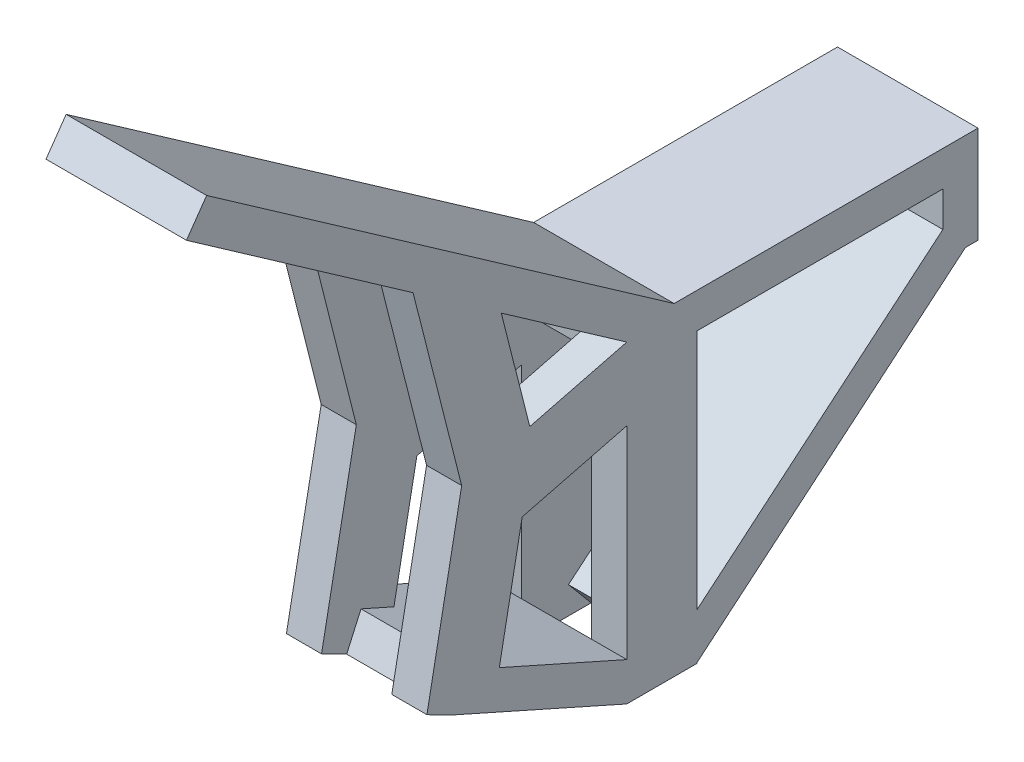
from build123d import *

# Parameters (mm, degrees)
SKETCH_1_W       = 160
SKETCH_1_H       = 40
EXTRUDE_1_DEPTH  = 400
EXTRUDE_6_DEPTH  = 160
SKETCH_11_W      = 40
SKETCH_11_H      = 40
EXTRUDE_7_DEPTH  = 160
EXTRUDE_11_DEPTH = 160
SKETCH_17_W      = 40
SKETCH_17_H      = 80
EXTRUDE_13_DEPTH = 328
EXTRUDE_17_DEPTH = 160
EXTRUDE_18_DEPTH = 40
SKETCH_29_W      = 40
SKETCH_29_H      = 210
EXTRUDE_19_DEPTH = 80
EXTRUDE_20_DEPTH = 40
EXTRUDE_21_DEPTH = 40
EXTRUDE_22_DEPTH = 40


with BuildPart() as part:
    # Эскиз1 → Бобышка-Вытянуть1 (new body)
    with BuildSketch(Plane.XY):
        with Locations((41.709401709, 20)):
            Rectangle(SKETCH_1_W, SKETCH_1_H)
    extrude(amount=EXTRUDE_1_DEPTH)

    # Эскиз8 → Бобышка-Вытянуть6 (add)
    with BuildSketch(Plane.ZY.offset(38.290598291)):
        Polygon((403.40525509, 80.13918018), (346.080564925, 40), (400, 40), (400, 28.923811345), (901.472451167, 380.058601857), (878.529393713, 412.824683628), align=None)
    extrude(amount=-EXTRUDE_6_DEPTH)

    # Эскиз11 → Бобышка-Вытянуть7 (add)
    with BuildSketch(Plane.ZY.offset(38.290598291)):
        with Locations((20, -20)):
            Rectangle(SKETCH_11_W, SKETCH_11_H)
    extrude(amount=-EXTRUDE_7_DEPTH)

    # Эскиз12 → Бобышка-Вытянуть11 (add)
    with BuildSketch(Plane.ZY.offset(38.290598291)):
        Polygon((346.417777248, -297.115043875), (40, -40), (0, -40), (0, -70.641777725), (14.288495613, -70.641777725), (320.70627286, -327.756821599), align=None)
    extrude(amount=-EXTRUDE_11_DEPTH)

    # Эскиз17 → Бобышка-Вытянуть13 (add)
    with BuildSketch(Plane(origin=(0, 0, 0), x_dir=(-1, 0, 0), z_dir=(0, -1, 0))):
        with Locations((18.290598291, -360)):
            Rectangle(SKETCH_17_W, SKETCH_17_H)
        with Locations((-101.709401709, -360)):
            Rectangle(SKETCH_17_W, SKETCH_17_H)
    extrude(amount=EXTRUDE_13_DEPTH)

    # Эскиз26 → Бобышка-Вытянуть17 (add)
    with BuildSketch(Plane.ZY.offset(38.290598291)):
        Polygon((400, -284.21454886), (400, -328), (416.269465723, -320.756367165), align=None)
        Polygon((582.709091529, -202.867220245), (598.978557252, -239.40903855), (416.269465723, -320.756367165), (400, -284.21454886), align=None)
    extrude(amount=-EXTRUDE_17_DEPTH)

    # Эскиз27 → Бобышка-Вытянуть18 (add)
    with BuildSketch(Plane.ZY.offset(38.290598291)):
        Polygon((509.482462661, -33.639974138), (588.04709667, -18.55361331), (616.334023223, -165.862302077), (537.769389214, -180.948662905), align=None)
        Polygon((545.18630579, -219.573440808), (582.709091529, -202.867220245), (595.238756951, -231.009309548), (627.648793843, -224.785777584), (616.334023223, -165.862302077), (537.769389214, -180.948662905), align=None)
        Polygon((627.648793843, -224.785777584), (595.238756951, -231.009309548), (598.978557252, -239.40903855), align=None)
    extrude(amount=-EXTRUDE_18_DEPTH)

    # Эскиз29 → Бобышка-Вытянуть19 (add)
    with BuildSketch(Plane(origin=(0, 108.244163778, 563.698774535), x_dir=(1, 0, 0), z_dir=(0, 0.18857951034822912, 0.9820579251127819))):
        with Locations((101.709401709, -234.114356543)):
            Rectangle(SKETCH_29_W, SKETCH_29_H)
    extrude(amount=-EXTRUDE_19_DEPTH)

    # Эскиз33 → Бобышка-Вытянуть20 (add)
    with BuildSketch(Plane(origin=(121.709401709, 0, 0), x_dir=(0, 0, -1), z_dir=(1, 0, 0))):
        Polygon((-627.648793843, -224.785777584), (-598.978557252, -239.40903855), (-595.238756951, -231.009309548), align=None)
    extrude(amount=-EXTRUDE_20_DEPTH)

    # Эскиз34 → Бобышка-Вытянуть21 (add)
    with BuildSketch(Plane.ZY.offset(38.290598291)):
        Polygon((400, -53.586571178), (490.897529352, -76.536037974), (510.481100679, 1.029958017), (400, 28.923811345), align=None)
        Polygon((510.481100679, 1.029958017), (490.897529352, -76.536037974), (514.961644961, -62.173691245), (509.482462661, -33.639974138), (588.04709667, -18.55361331), align=None)
        Polygon((514.961644961, -62.173691245), (490.897529352, -76.536037974), (519.0862075, -83.653009555), align=None)
        Polygon((542.761910091, 128.886776961), (510.481100679, 1.029958017), (588.04709667, -18.55361331), (642.991448698, 199.068255444), align=None)
    extrude(amount=-EXTRUDE_21_DEPTH)

    # Эскиз35 → Бобышка-Вытянуть22 (add)
    with BuildSketch(Plane(origin=(121.709401709, 0, 0), x_dir=(0, 0, -1), z_dir=(1, 0, 0))):
        Polygon((-588.04709667, -18.55361331), (-643.423626769, 199.370869787), (-543.015704436, 129.064485674), (-510.437956524, 0.860554126), (-400, 28.923811345), (-400, -53.618639699), (-519.131929063, -83.891111895), (-509.482462661, -33.639974138), align=None)
    extrude(amount=-EXTRUDE_22_DEPTH)


solid = part.part
